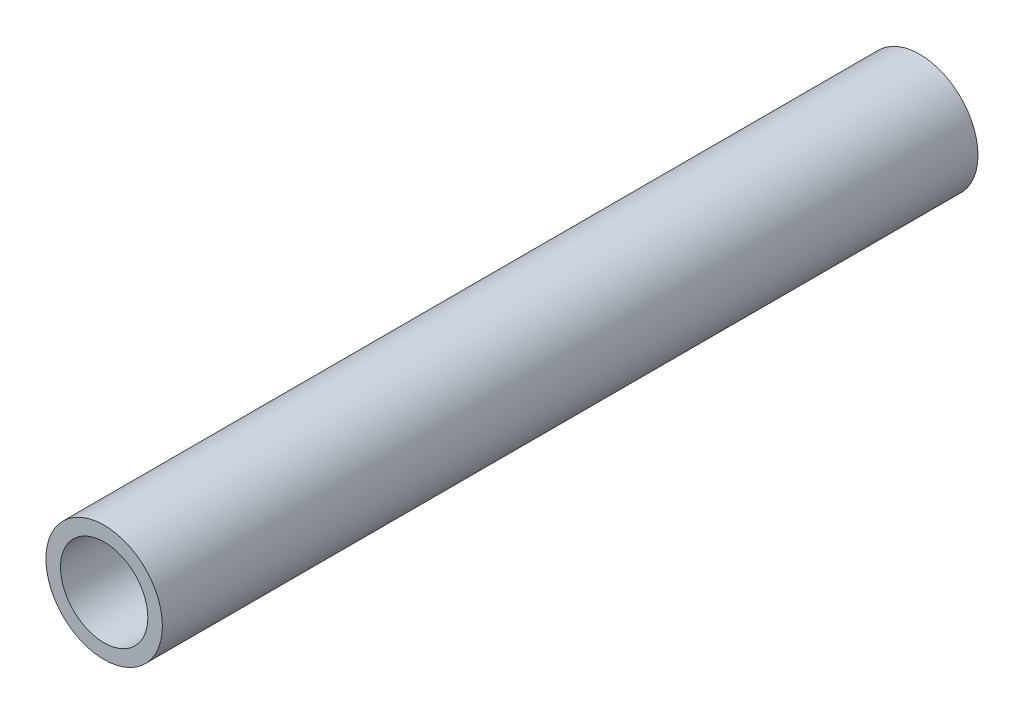
from build123d import *

# Parameters (mm, degrees)
SKETCH1_R           = 12.7
SKETCH1_R_2         = 9.525
BOSS_EXTRUDE1_DEPTH = 177.8


with BuildPart() as part:
    # Sketch1 → Boss-Extrude1 (new body)
    with BuildSketch(Plane.XY):
        Circle(SKETCH1_R)
        Circle(SKETCH1_R_2, mode=Mode.SUBTRACT)
    extrude(amount=BOSS_EXTRUDE1_DEPTH)


solid = part.part
